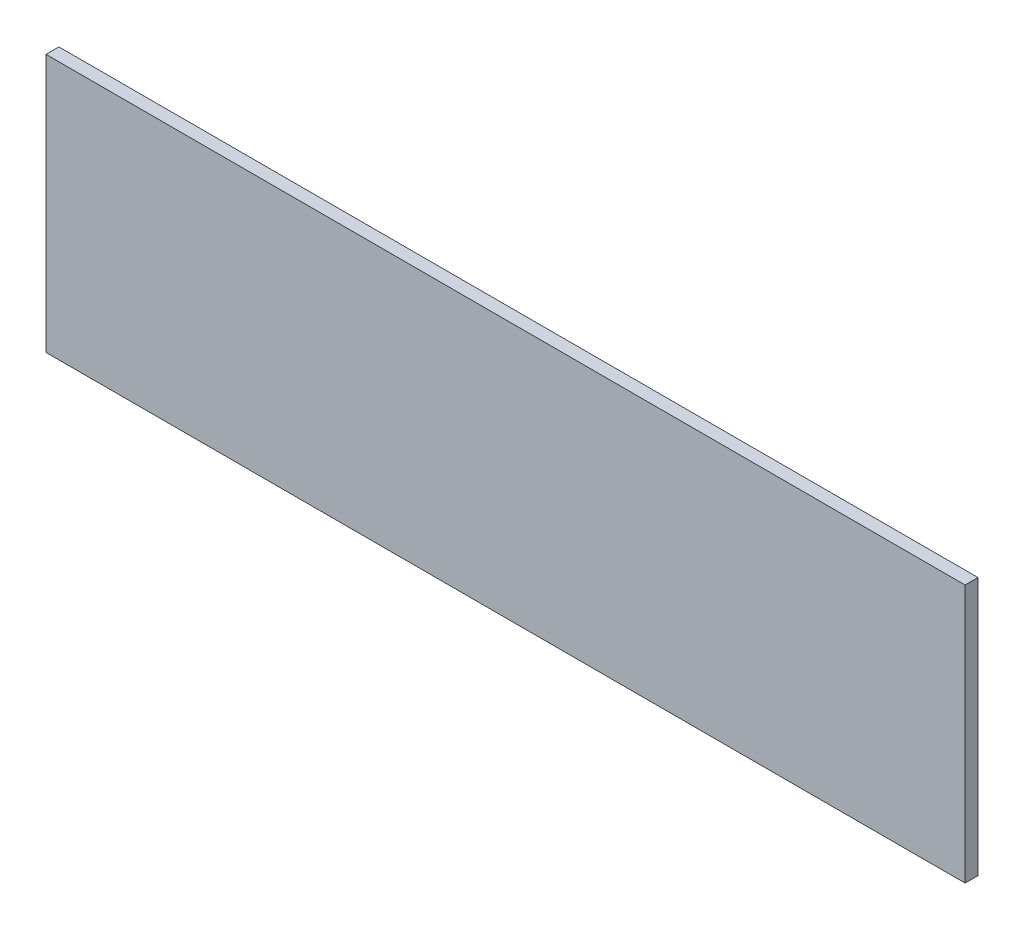
from build123d import *

# Parameters (mm, degrees)
ESQUISSE1_W        = 356
ESQUISSE1_H        = 100
BOSS_EXTRU_1_DEPTH = 5


with BuildPart() as part:
    # Esquisse1 → Boss.-Extru.1 (new body)
    with BuildSketch(Plane.XY):
        with Locations((-178, 50)):
            Rectangle(ESQUISSE1_W, ESQUISSE1_H)
    extrude(amount=BOSS_EXTRU_1_DEPTH)


solid = part.part
